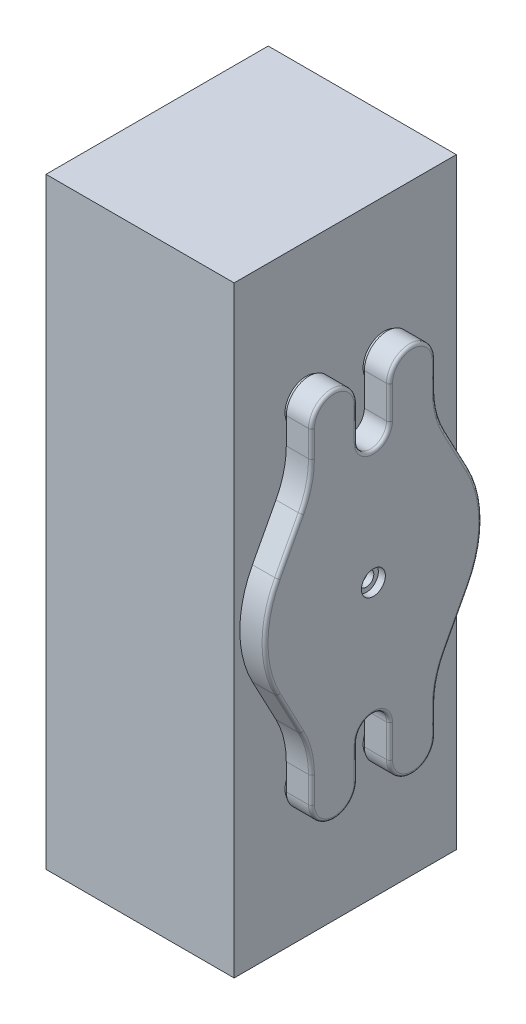
from build123d import *

# Parameters (mm, degrees)
SKETCH1_W           = 18
SKETCH1_H           = 18.25
SKETCH2_R           = 3.7145
CUT_EXTRUDE1_DEPTH  = 8.5725
SKETCH3_R           = 18.25
BOSS_EXTRUDE1_DEPTH = 8.5
SKETCH4_R           = 6.4
SKETCH4_R_2         = 4.75
BOSS_EXTRUDE2_DEPTH = 52
FILLET1_R           = 1
SKETCH6_R           = 18.25
CUT_EXTRUDE2_DEPTH  = 22
SKETCH10_W          = 75
SKETCH10_H          = 203.2
SKETCH10_R          = 7.15
SKETCH10_R_2        = 18.75
BOSS_EXTRUDE3_DEPTH = 63.5
SKETCH11_R          = 2.25
CUT_EXTRUDE5_DEPTH  = 6
SKETCH12_R          = 2.5
SKETCH12_R_2        = 4.05
CUT_EXTRUDE6_DEPTH  = 2.36
SKETCH12_3_R        = 2.5
CUT_EXTRUDE7_DEPTH  = 4.5


with BuildPart() as part:
    # Sketch1 → Revolve1 (revolve)
    with BuildSketch(Plane.XY):
        with Locations((17.255, 9.125)):
            Rectangle(SKETCH1_W, SKETCH1_H)
    revolve(axis=Axis((8.255, 0, 0), (1, 0, 0)))

    # Sketch2 → Cut-Extrude1 (cut)
    with BuildSketch(Plane.ZY.offset(-8.255)):
        Circle(SKETCH2_R)
    extrude(amount=-CUT_EXTRUDE1_DEPTH, mode=Mode.SUBTRACT)


with BuildPart() as body_2:
    # Sketch3 → Boss-Extrude1 (new body)
    with BuildSketch(Plane(origin=(26.255, 0, 0), x_dir=(0, 0, -1), z_dir=(1, 0, 0))):
        with BuildLine():
            Line((-24.382347836, 32.115154563), (-32.324530318, 17.115154563))
            ThreePointArc((-32.324530318, 17.115154563), (-36.576, 0), (-32.324530318, -17.115154563))
            Line((-32.324530318, -17.115154563), (-24.382347836, -32.115154563))
            ThreePointArc((-24.382347836, -32.115154563), (-21.780072988, -38.920854003), (-20.89525, -46.153175037))
            Line((-20.89525, -46.153175037), (-20.89525, -55))
            ThreePointArc((-20.89525, -55), (-13.175, -62.72025), (-5.45475, -55))
            Line((-5.45475, -55), (-5.45475, -44))
            ThreePointArc((-5.45475, -44), (0, -38.54525), (5.45475, -44))
            Line((5.45475, -44), (5.45475, -55))
            ThreePointArc((5.45475, -55), (13.175, -62.72025), (20.89525, -55))
            Line((20.89525, -55), (20.89525, -46.153175037))
            ThreePointArc((20.89525, -46.153175037), (21.780072988, -38.920854003), (24.382347836, -32.115154563))
            Line((24.382347836, -32.115154563), (32.324530318, -17.115154563))
            ThreePointArc((32.324530318, -17.115154563), (36.576, 0), (32.324530318, 17.115154563))
            Line((32.324530318, 17.115154563), (24.382347836, 32.115154563))
            ThreePointArc((24.382347836, 32.115154563), (21.780072988, 38.920854003), (20.89525, 46.153175037))
            Line((20.89525, 46.153175037), (20.89525, 55))
            ThreePointArc((20.89525, 55), (13.175, 62.72025), (5.45475, 55))
            Line((5.45475, 55), (5.45475, 44))
            ThreePointArc((5.45475, 44), (0, 38.54525), (-5.45475, 44))
            Line((-5.45475, 44), (-5.45475, 55))
            ThreePointArc((-5.45475, 55), (-13.175, 62.72025), (-20.89525, 55))
            Line((-20.89525, 55), (-20.89525, 46.153175037))
            ThreePointArc((-20.89525, 46.153175037), (-21.780072988, 38.920854003), (-24.382347836, 32.115154563))
        make_face()
        Circle(SKETCH3_R, mode=Mode.SUBTRACT)
        Circle(SKETCH3_R)
    extrude(amount=BOSS_EXTRUDE1_DEPTH)

    # Sketch4 → Boss-Extrude2 (add)
    with BuildSketch(Plane.ZY.offset(-26.255)):
        with Locations((-13.175, 55)):
            Circle(SKETCH4_R)
        with Locations((-13.175, 55)):
            Circle(SKETCH4_R_2, mode=Mode.SUBTRACT)
        with Locations((13.175, 55)):
            Circle(SKETCH4_R)
        with Locations((13.175, 55)):
            Circle(SKETCH4_R_2, mode=Mode.SUBTRACT)
        with Locations((13.175, -55)):
            Circle(SKETCH4_R)
        with Locations((13.175, -55)):
            Circle(SKETCH4_R_2, mode=Mode.SUBTRACT)
        with Locations((-13.175, -55)):
            Circle(SKETCH4_R)
        with Locations((-13.175, -55)):
            Circle(SKETCH4_R_2, mode=Mode.SUBTRACT)
    extrude(amount=BOSS_EXTRUDE2_DEPTH)

    # Fillet1
    fillet1_edges = [body_2.edges().sort_by_distance(p)[0] for p in [
        (34.755, 0, 36.576),
        (34.755, 38.54525, 0),
        (34.755, 49.5, 5.45475),
        (34.755, 62.72025, 13.175),
        (34.755, 50.576587519, 20.89525),
        (34.755, 38.920854003, 21.780072988),
        (34.755, -24.615154563, 28.353439077),
        (34.755, -38.920854003, 21.780072988),
        (34.755, -50.576587519, 20.89525),
        (34.755, -62.72025, 13.175),
        (34.755, -49.5, 5.45475),
        (34.755, -38.54525, 0),
        (34.755, -49.5, -5.45475),
        (34.755, 24.615154563, 28.353439077),
        (34.755, -62.72025, -13.175),
        (34.755, -50.576587519, -20.89525),
        (34.755, -38.920854003, -21.780072988),
        (34.755, -24.615154563, -28.353439077),
        (34.755, 0, -36.576),
        (34.755, 24.615154563, -28.353439077),
        (34.755, 38.920854003, -21.780072988),
        (34.755, 50.576587519, -20.89525),
        (34.755, 62.72025, -13.175),
        (34.755, 49.5, -5.45475),
    ]]
    fillet(fillet1_edges, radius=FILLET1_R)


with BuildPart() as cut_extrude2_tool:
    # Sketch6 → Cut-Extrude2 (new body)
    with BuildSketch(Plane.ZY.offset(-8.255)):
        Circle(SKETCH6_R)
    extrude(amount=-CUT_EXTRUDE2_DEPTH)


with BuildPart() as part_1:
    add(part.part)

    # Cut-Extrude2: cut by cut_extrude2_tool
    add(cut_extrude2_tool.part, mode=Mode.SUBTRACT)


with BuildPart() as body_2_1:
    add(body_2.part)

    # Cut-Extrude2: cut by cut_extrude2_tool
    add(cut_extrude2_tool.part, mode=Mode.SUBTRACT)

    # Sketch12 → Cut-Extrude6 (cut)
    with BuildSketch(Plane(origin=(34.755, 0, 0), x_dir=(0, 0, -1), z_dir=(1, 0, 0))):
        Circle(SKETCH12_R)
        Circle(SKETCH12_R_2)
        Circle(SKETCH12_R, mode=Mode.SUBTRACT)
    extrude(amount=-CUT_EXTRUDE6_DEPTH, mode=Mode.SUBTRACT)

    # Sketch12_3 → Cut-Extrude7 (cut)
    with BuildSketch(Plane(origin=(34.755, 0, 0), x_dir=(0, 0, -1), z_dir=(1, 0, 0))):
        Circle(SKETCH12_3_R)
    extrude(amount=-CUT_EXTRUDE7_DEPTH, mode=Mode.SUBTRACT)


with BuildPart() as body_2_2:
    # Sketch10 → Boss-Extrude3 (new body)
    with BuildSketch(Plane.ZY.offset(-25.255)):
        Rectangle(SKETCH10_W, SKETCH10_H)
        with Locations((-13.175, 55)):
            Circle(SKETCH10_R, mode=Mode.SUBTRACT)
        with Locations((13.175, 55)):
            Circle(SKETCH10_R, mode=Mode.SUBTRACT)
        with Locations((-13.175, -55)):
            Circle(SKETCH10_R, mode=Mode.SUBTRACT)
        with Locations((13.175, -55)):
            Circle(SKETCH10_R, mode=Mode.SUBTRACT)
        Circle(SKETCH10_R_2, mode=Mode.SUBTRACT)
    extrude(amount=BOSS_EXTRUDE3_DEPTH)

    # Sketch11 → Cut-Extrude5 (cut)
    with BuildSketch(Plane.XZ.offset(101.6)):
        with Locations((-21.495, 27.5)):
            Circle(SKETCH11_R)
        with Locations((8.505, 27.5)):
            Circle(SKETCH11_R)
        with Locations((-21.495, -27.5)):
            Circle(SKETCH11_R)
        with Locations((8.505, -27.5)):
            Circle(SKETCH11_R)
    extrude(amount=-CUT_EXTRUDE5_DEPTH, mode=Mode.SUBTRACT)


solid = Compound([body_2_1.part, body_2_2.part])
